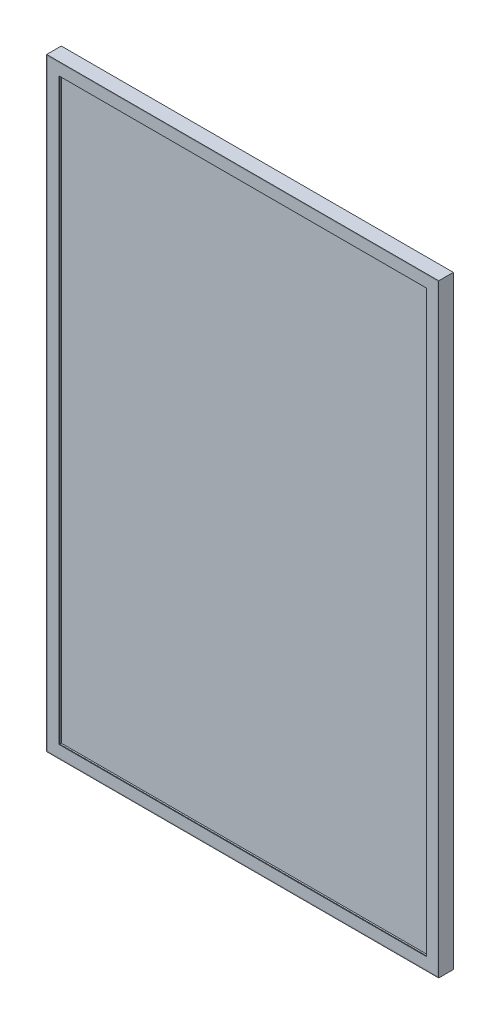
from build123d import *

# Parameters (mm, degrees)
SKETCH_1_W      = 537
SKETCH_1_H      = 827
EXTRUDE_1_DEPTH = 20
SHELL_1_T       = -1
SKETCH_3_W      = 535
SKETCH_3_H      = 825
SKETCH_3_W_2    = 503
SKETCH_3_H_2    = 793
EXTRUDE_2_DEPTH = 1


with BuildPart() as part:
    # 草图1 → 凸台-拉伸1 (new body)
    with BuildSketch(Plane.XY):
        Rectangle(SKETCH_1_W, SKETCH_1_H)
    extrude(amount=EXTRUDE_1_DEPTH)

    # 抽壳1
    shell_1_openings = [part.faces().sort_by_distance(p)[0] for p in [
        (0, 0, 20),
    ]]
    offset(amount=SHELL_1_T, openings=shell_1_openings, kind=Kind.INTERSECTION)


with BuildPart() as body_2:
    # 草图3 → 凸台-拉伸2 (new body)
    with BuildSketch(Plane.XY.offset(20)):
        Rectangle(SKETCH_3_W, SKETCH_3_H)
        Rectangle(SKETCH_3_W_2, SKETCH_3_H_2, mode=Mode.SUBTRACT)
    extrude(amount=-EXTRUDE_2_DEPTH)


solid = Compound([part.part, body_2.part])
